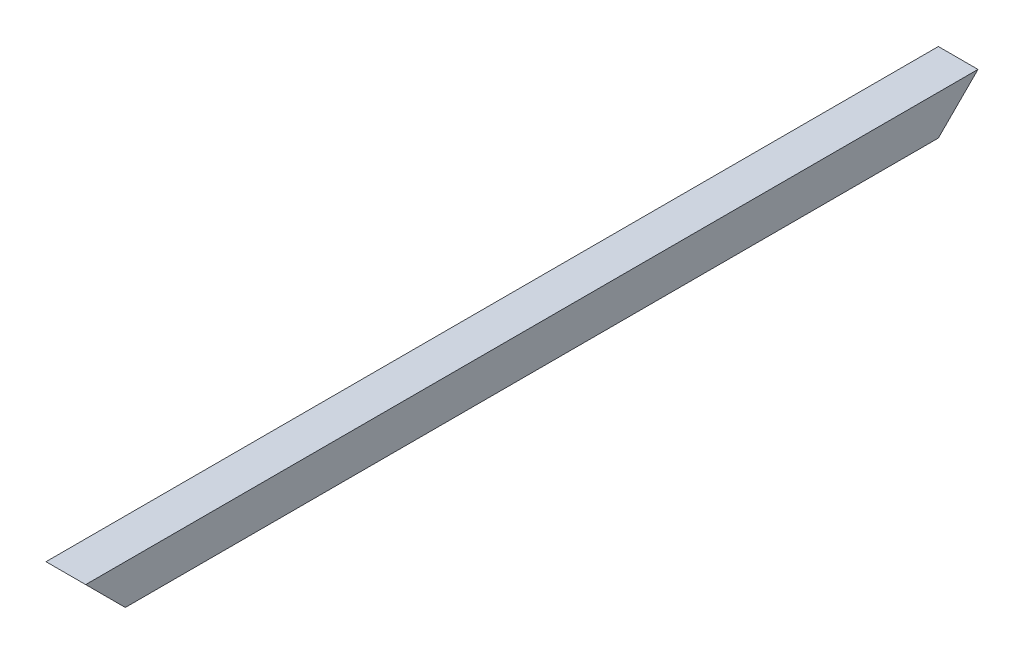
from build123d import *

# Parameters (mm, degrees)
SKETCH1_W               = 100
SKETCH1_H               = 100
SKETCH1_W_2             = 90
SKETCH1_H_2             = 90
BOSS_EXTRUDE1_DEPTH     = 1125
CUT_EXTRUDE1_DEPTH      = 51
CUT_EXTRUDE1_DEPTH_BACK = 51


with BuildPart() as part:
    # Sketch1 → Boss-Extrude1 (new body, symmetric)
    with BuildSketch(Plane.XY):
        Rectangle(SKETCH1_W, SKETCH1_H)
        Rectangle(SKETCH1_W_2, SKETCH1_H_2, mode=Mode.SUBTRACT)
    extrude(amount=BOSS_EXTRUDE1_DEPTH, both=True)

    # Sketch4 → Cut-Extrude1 (cut, two sides)
    with BuildSketch(Plane(origin=(0, 0, 0), x_dir=(0, 0, -1), z_dir=(1, 0, 0))) as cut_extrude1_sk:
        Polygon((-1125, 50), (-1025, -50), (-1125, -50), align=None)
        Polygon((1125, 50), (1025, -50), (1125, -50), align=None)
    extrude(amount=CUT_EXTRUDE1_DEPTH, mode=Mode.SUBTRACT)
    extrude(cut_extrude1_sk.sketch, amount=-CUT_EXTRUDE1_DEPTH_BACK, mode=Mode.SUBTRACT)


solid = part.part
